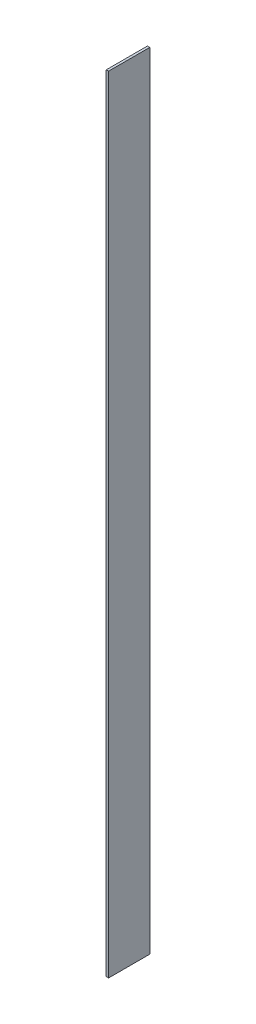
from build123d import *

# Parameters (mm, degrees)
SKETCH1_W           = 21
SKETCH1_H           = 400
BOSS_EXTRUDE1_DEPTH = 0.6


with BuildPart() as part:
    # Sketch1 → Boss-Extrude1 (new body, symmetric)
    with BuildSketch(Plane(origin=(0, 0, 0), x_dir=(0, 0, -1), z_dir=(1, 0, 0))):
        Rectangle(SKETCH1_W, SKETCH1_H)
    extrude(amount=BOSS_EXTRUDE1_DEPTH, both=True)


solid = part.part
